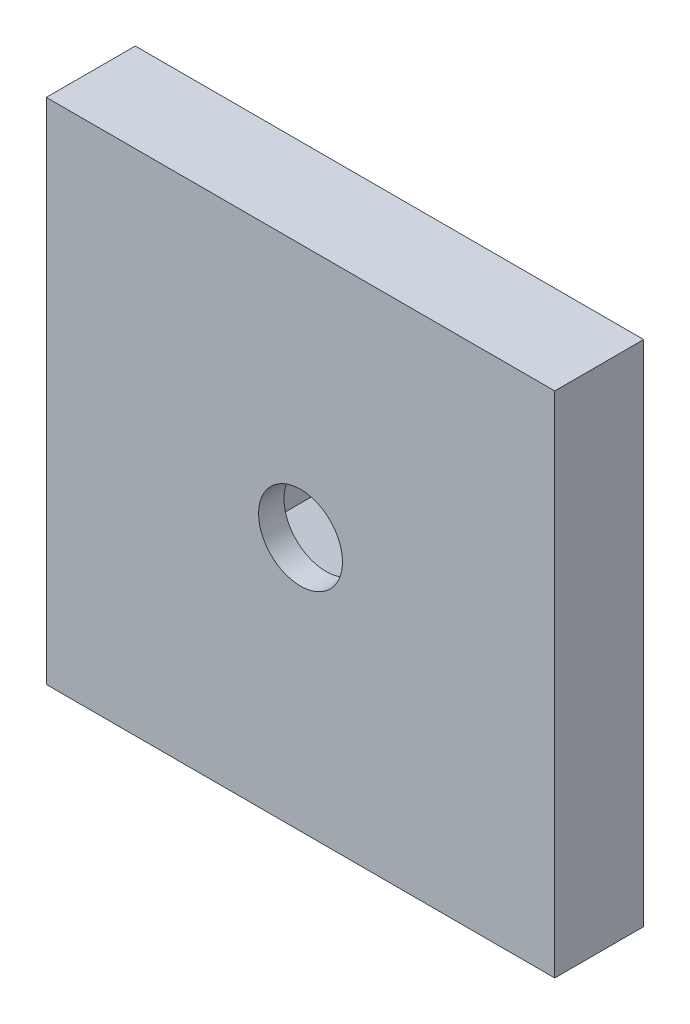
from build123d import *

# Parameters (mm, degrees)
SKETCH1_W           = 20
SKETCH1_H           = 20
BOSS_EXTRUDE1_DEPTH = 2.5
SKETCH2_W           = 20
SKETCH2_H           = 20
BOSS_EXTRUDE2_DEPTH = 1
SKETCH3_R           = 1.65
CUT_EXTRUDE1_DEPTH  = 4.5


with BuildPart() as part:
    # Sketch1 → Boss-Extrude1 (new body)
    with BuildSketch(Plane.XY):
        Rectangle(SKETCH1_W, SKETCH1_H)
        Polygon((0, -3.210067497), (2.78, -1.605033748), (2.78, 1.605033748), (0, 3.210067497), (-2.78, 1.605033748), (-2.78, -1.605033748), align=None, mode=Mode.SUBTRACT)
    extrude(amount=BOSS_EXTRUDE1_DEPTH)

    # Sketch2 → Boss-Extrude2 (add)
    with BuildSketch(Plane.XY.offset(2.5)):
        Rectangle(SKETCH2_W, SKETCH2_H)
    extrude(amount=BOSS_EXTRUDE2_DEPTH)

    # Sketch3 → Cut-Extrude1 (cut, through all)
    with BuildSketch(Plane(origin=(0, 0, 0), x_dir=(-1, 0, 0), z_dir=(0, 0, -1))):
        Circle(SKETCH3_R)
    extrude(amount=-CUT_EXTRUDE1_DEPTH, mode=Mode.SUBTRACT)


solid = part.part
